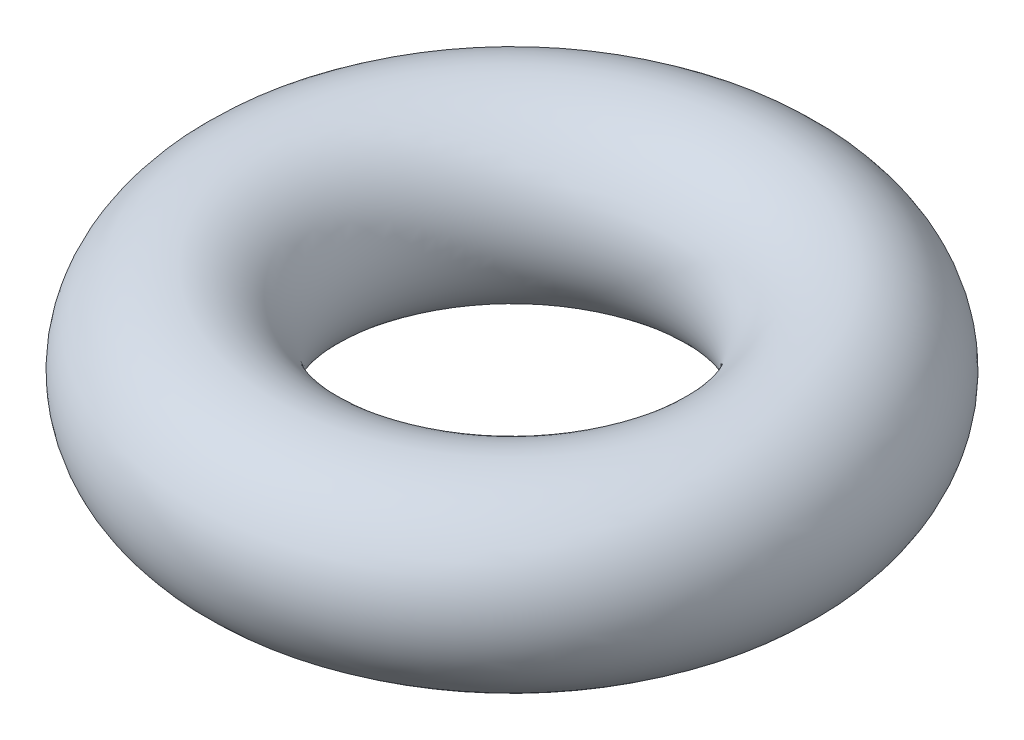
from build123d import *

# Parameters (mm, degrees)
SKETCH_1_R = 11.768980609


with BuildPart() as part:
    # 扫描1: sweep along a path in 草图2
    with BuildLine(Plane(origin=(0, 0, 0), x_dir=(1, 0, 0), z_dir=(0, 1, 0))) as sweep_1_path:
        CenterArc((30.883327985, 0), 30.883327985, 0, 360)
    # 草图1 → 扫描1 (sweep)
    with BuildSketch(Plane.XY):
        Circle(SKETCH_1_R)
    sweep(path=sweep_1_path.line)


solid = part.part
